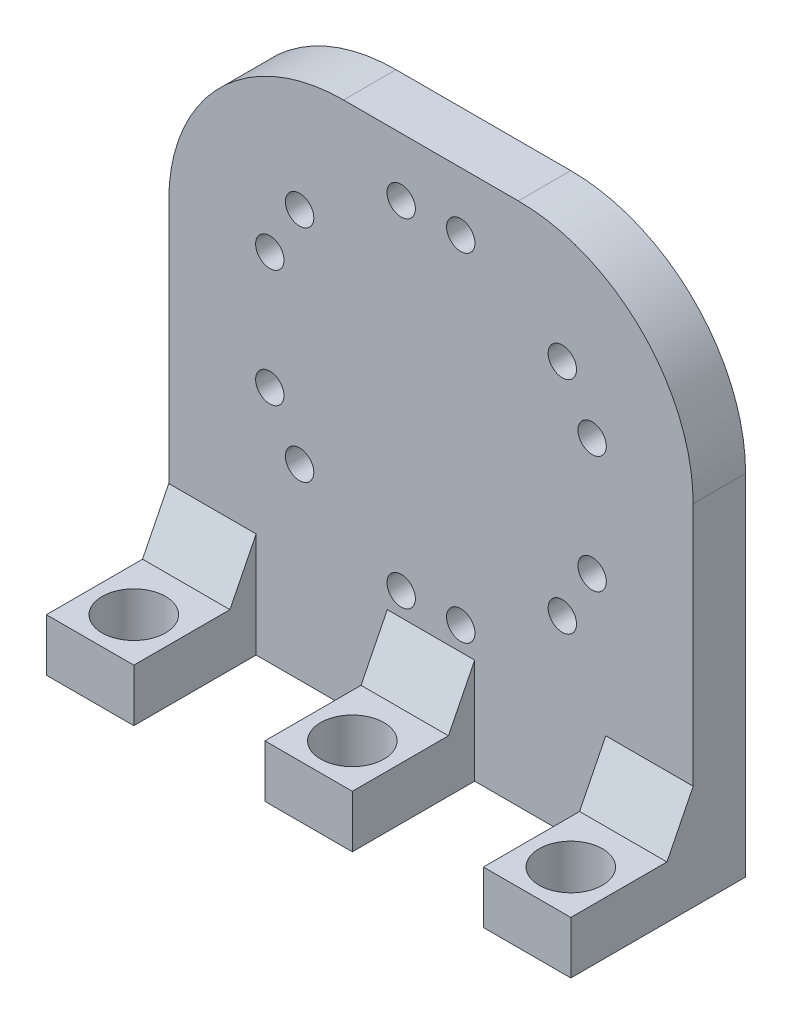
from build123d import *

# Parameters (mm, degrees)
SKETCH1_W           = 60
SKETCH1_H           = 60
BOSS_EXTRUDE1_DEPTH = 6
SKETCH2_W           = 10
SKETCH2_H           = 6
BOSS_EXTRUDE2_DEPTH = 14
BOSS_EXTRUDE3_DEPTH = 10
SKETCH4_R           = 3.625
CUT_EXTRUDE1_DEPTH  = 15
LPATTERN2_COUNT     = 3
LPATTERN2_PITCH     = 25
SKETCH5_R           = 1.625
CUT_EXTRUDE2_DEPTH  = 15
CIRPATTERN2_COUNT   = 6
FILLET1_R           = 20


with BuildPart() as part:
    # Sketch1 → Boss-Extrude1 (new body)
    with BuildSketch(Plane.XY):
        Rectangle(SKETCH1_W, SKETCH1_H)
    extrude(amount=BOSS_EXTRUDE1_DEPTH)

    # Sketch2 → Boss-Extrude2 (add)
    with BuildSketch(Plane.XY.offset(6)):
        with Locations((25, -27)):
            Rectangle(SKETCH2_W, SKETCH2_H)
    boss_extrude2 = extrude(amount=BOSS_EXTRUDE2_DEPTH)

    # Sketch3 → Boss-Extrude3 (add)
    with BuildSketch(Plane(origin=(30, 0, 0), x_dir=(0, 0, -1), z_dir=(1, 0, 0))):
        Polygon((-6, -18), (-9, -24), (-6, -24), align=None)
    boss_extrude3 = extrude(amount=-BOSS_EXTRUDE3_DEPTH)

    # Sketch4 → Cut-Extrude1 (cut)
    with BuildSketch(Plane(origin=(0, -24, 0), x_dir=(1, 0, 0), z_dir=(0, 1, 0))):
        with Locations((25, -15)):
            Circle(SKETCH4_R)
    cut_extrude1 = extrude(amount=-CUT_EXTRUDE1_DEPTH, mode=Mode.SUBTRACT)

    # LPattern2: Boss-Extrude2, Boss-Extrude3, Cut-Extrude1 ×3
    with Locations(*[(-i * LPATTERN2_PITCH, 0, 0) for i in range(1, LPATTERN2_COUNT)]):
        add(boss_extrude2)
        add(boss_extrude3)
        add(cut_extrude1, mode=Mode.SUBTRACT)

    # Sketch5 → Cut-Extrude2 (cut)
    with BuildSketch(Plane(origin=(0, 0, 0), x_dir=(-1, 0, 0), z_dir=(0, 0, -1))):
        with Locations((3.406977246, 23.321928114)):
            Circle(SKETCH5_R)
        with Locations((-3.406977246, 23.321928114)):
            Circle(SKETCH5_R)
    cut_extrude2 = extrude(amount=-CUT_EXTRUDE2_DEPTH, mode=Mode.SUBTRACT)

    # CirPattern2: Cut-Extrude2 ×6 about axis
    cirpattern2_axis = Axis((0, 4, 0), (0, 0, 1))
    for i in range(1, CIRPATTERN2_COUNT):
        add(cut_extrude2.rotate(cirpattern2_axis, i * 360 / CIRPATTERN2_COUNT), mode=Mode.SUBTRACT)

    # Fillet1
    fillet1_edges = [part.edges().sort_by_distance(p)[0] for p in [
        (-30, 30, 3),
        (30, 30, 3),
    ]]
    fillet(fillet1_edges, radius=FILLET1_R)


solid = part.part
